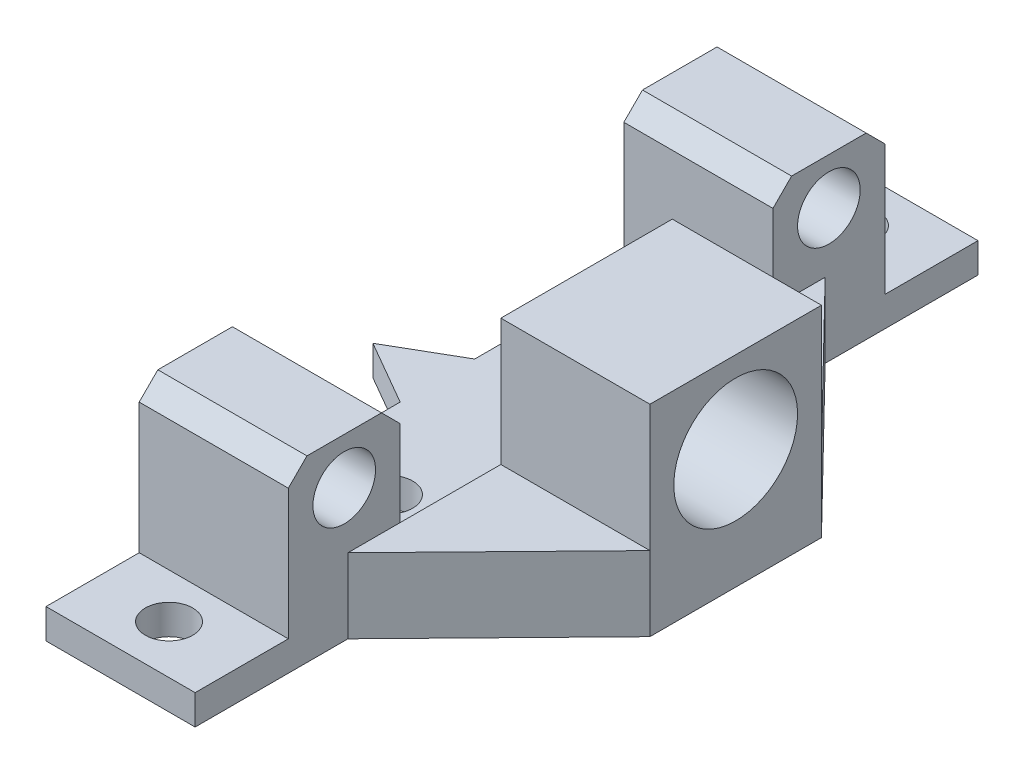
from build123d import *

# Parameters (mm, degrees)
SKETCH1_W           = 20
SKETCH1_H           = 105
BOSS_EXTRUDE1_DEPTH = 4
SKETCH2_R           = 4.2
BOSS_EXTRUDE2_DEPTH = 20
BOSS_EXTRUDE3_DEPTH = 4
SKETCH4_R           = 3.175
CUT_EXTRUDE1_DEPTH  = 5
SKETCH5_W           = 23
SKETCH5_H           = 27
BOSS_EXTRUDE4_DEPTH = 20
SKETCH6_R           = 8.3
CUT_EXTRUDE2_DEPTH  = 49.660254038
BOSS_EXTRUDE5_DEPTH = 10


with BuildPart() as part:
    # Sketch1 → Boss-Extrude1 (new body)
    with BuildSketch(Plane(origin=(0, 0, 0), x_dir=(1, 0, 0), z_dir=(0, 1, 0))):
        with Locations((10, 52.5)):
            Rectangle(SKETCH1_W, SKETCH1_H)
    extrude(amount=BOSS_EXTRUDE1_DEPTH)

    # Sketch2 → Boss-Extrude2 (add)
    with BuildSketch(Plane.ZY):
        Polygon((-12.5, 4), (-12.5, 21.5), (-15, 24), (-25, 24), (-27.5, 21.5), (-27.5, 4), align=None)
        with Locations((-20, 17.8)):
            Circle(SKETCH2_R, mode=Mode.SUBTRACT)
        Polygon((-92.5, 4), (-77.5, 4), (-77.5, 21.5), (-80, 24), (-90, 24), (-92.5, 21.5), align=None)
        with Locations((-85, 17.8)):
            Circle(SKETCH2_R, mode=Mode.SUBTRACT)
    extrude(amount=-BOSS_EXTRUDE2_DEPTH)

    # Sketch3 → Boss-Extrude3 (add)
    with BuildSketch(Plane.XZ):
        Polygon((0, -57.5), (-8.660254038, -52.5), (0, -47.5), align=None)
    extrude(amount=-BOSS_EXTRUDE3_DEPTH)

    # Sketch4 → Cut-Extrude1 (cut, through all)
    with BuildSketch(Plane(origin=(0, 4, 0), x_dir=(1, 0, 0), z_dir=(0, 1, 0))):
        with Locations((10, 98.5)):
            Circle(SKETCH4_R)
        with Locations((10, 69)):
            Circle(SKETCH4_R)
        with Locations((10, 36)):
            Circle(SKETCH4_R)
        with Locations((10, 6.5)):
            Circle(SKETCH4_R)
    extrude(amount=-CUT_EXTRUDE1_DEPTH, mode=Mode.SUBTRACT)

    # Sketch5 → Boss-Extrude4 (add)
    with BuildSketch(Plane(origin=(20, 0, 0), x_dir=(0, 0, -1), z_dir=(1, 0, 0))):
        with Locations((52.5, 13.5)):
            Rectangle(SKETCH5_W, SKETCH5_H)
    extrude(amount=BOSS_EXTRUDE4_DEPTH)

    # Sketch6 → Cut-Extrude2 (cut, through all)
    with BuildSketch(Plane(origin=(40, 0, 0), x_dir=(0, 0, -1), z_dir=(1, 0, 0))):
        with Locations((52.5, 16)):
            Circle(SKETCH6_R)
    extrude(amount=-CUT_EXTRUDE2_DEPTH, mode=Mode.SUBTRACT)

    # Sketch11 → Boss-Extrude5 (add)
    with BuildSketch(Plane.XZ):
        Polygon((40, -64), (20, -84.5), (20, -64), align=None)
        Polygon((40, -41), (20, -41), (20, -20.5), align=None)
    extrude(amount=-BOSS_EXTRUDE5_DEPTH)


solid = part.part
